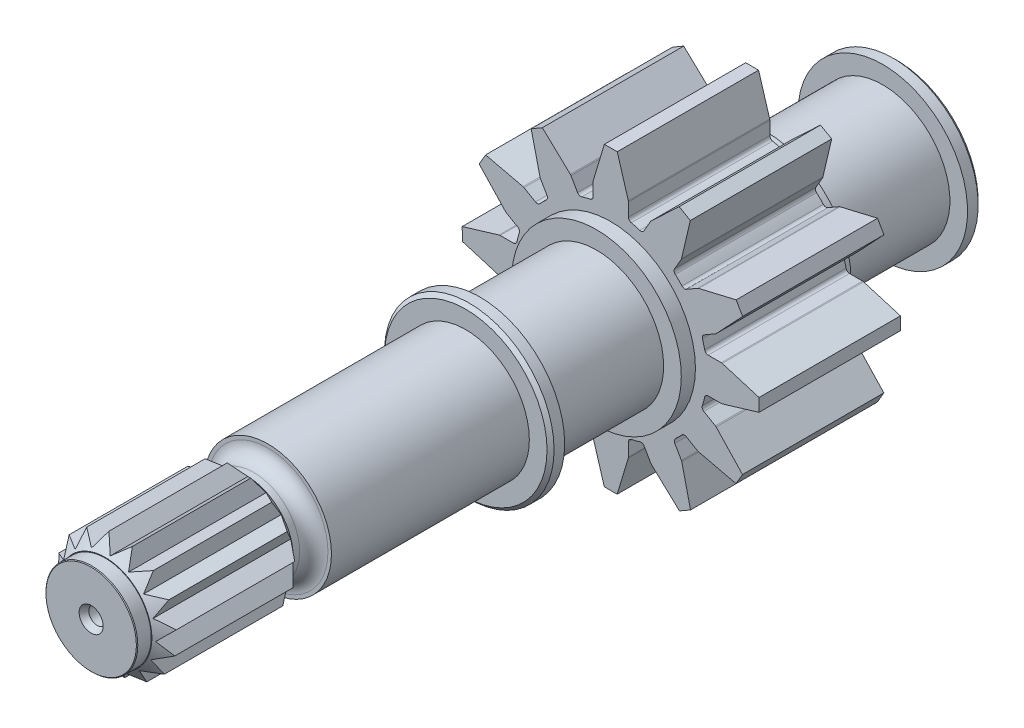
from build123d import *

# Parameters (mm, degrees)
EXTRUDE_1_DEPTH      = 20
SKETCH_3_R           = 12
EXTRUDE_2_DEPTH      = 2
SKETCH_4_R           = 12
EXTRUDE_3_DEPTH      = 2
SKETCH_5_R           = 9.5
EXTRUDE_4_DEPTH      = 16.5
SKETCH_6_R           = 12
EXTRUDE_5_DEPTH      = 2
CHAMFER_2_SIZE       = 0.5
SKETCH_7_R           = 9.5
EXTRUDE_6_DEPTH      = 16.5
SKETCH_8_R           = 12
EXTRUDE_7_DEPTH      = 2
CHAMFER_3_SIZE       = 0.5
SKETCH_10_R          = 9
EXTRUDE_9_DEPTH      = 28
SKETCH_11_R          = 6.5
EXTRUDE_10_DEPTH     = 3
FILLET_1_R           = 2
EXTRUDE_11_DEPTH     = 20
SKETCH_13_R          = 6.5
EXTRUDE_12_DEPTH     = 2
CHAMFER_5_SIZE       = 0.1
SKETCH_15_R          = 2.5
CUT_EXTRUDE_13_DEPTH = 74
CHAMFER_6_SIZE       = 0.5
CHAMFER_6_SIZE2      = 0.866025404
SKETCH_16_R          = 1
CUT_EXTRUDE_14_DEPTH = 9
SKETCH_17_R          = 1.2
CUT_EXTRUDE_15_DEPTH = 7
CHAMFER_7_SIZE       = 0.5
CHAMFER_7_SIZE2      = 0.866025404


with BuildPart() as part:
    # Эскиз2 → Вытянуть1 (new body)
    with BuildSketch(Plane.XY):
        with BuildLine():
            Line((53.764538287, -2.946020686), (53.764538287, -1.077143616))
            ThreePointArc((53.764538287, -1.077143616), (53.759197394, -1.004257629), (53.743288818, -0.932928746))
            Line((53.743288818, -0.932928746), (52.174732421, 4.274212553))
            Line((52.174732421, 4.274212553), (50.354570926, 4.274212553))
            Line((50.354570926, 4.274212553), (48.785793437, -0.932919949))
            ThreePointArc((48.785793437, -0.932919949), (48.769880615, -1.004257948), (48.764538287, -1.077153679))
            Line((48.764538287, -1.077153679), (48.764538287, -2.953138509))
            ThreePointArc((48.764538287, -2.953138509), (48.653798767, -3.266947811), (48.370633173, -3.441752748))
            ThreePointArc((48.370633173, -3.441752748), (47.755574297, -3.590379289), (47.148101498, -3.767478327))
            ThreePointArc((47.148101498, -3.767478327), (46.816157953, -3.756991645), (46.564008916, -3.540849677))
            Line((46.564008916, -3.540849677), (45.628704767, -1.920855369))
            ThreePointArc((45.628704767, -1.920855369), (45.587636424, -1.860404698), (45.538194752, -1.806586362))
            Line((45.538194752, -1.806586362), (41.576214415, 1.918652085))
            Line((41.576214415, 1.918652085), (39.999908322, 1.008571338))
            Line((39.999908322, 1.008571338), (41.244873414, -4.285326434))
            ThreePointArc((41.244873414, -4.285326434), (41.266761505, -4.355063364), (41.298582779, -4.420864083))
            Line((41.298582779, -4.420864083), (42.233043669, -6.039397823))
            ThreePointArc((42.233043669, -6.039397823), (42.29400173, -6.366811555), (42.135803463, -6.659879713))
            ThreePointArc((42.135803463, -6.659879713), (41.671118276, -7.10145189), (41.227792451, -7.564464333))
            ThreePointArc((41.227792451, -7.564464333), (40.935062472, -7.721409797), (40.608582641, -7.660306282))
            Line((40.608582641, -7.660306282), (38.980519219, -6.720343428))
            ThreePointArc((38.980519219, -6.720343428), (38.914727656, -6.688525782), (38.845000744, -6.666638572))
            Line((38.845000744, -6.666638572), (33.551205899, -5.42147761))
            Line((33.551205899, -5.42147761), (32.641125152, -6.997783703))
            Line((32.641125152, -6.997783703), (36.36624071, -10.959946087))
            ThreePointArc((36.36624071, -10.959946087), (36.42007011, -11.009400187), (36.480534902, -11.050477203))
            Line((36.480534902, -11.050477203), (38.099195221, -11.984952893))
            ThreePointArc((38.099195221, -11.984952893), (38.3156739, -12.237948594), (38.325284093, -12.570781115))
            ThreePointArc((38.325284093, -12.570781115), (38.135802793, -13.215524272), (37.978453065, -13.868852647))
            ThreePointArc((37.978453065, -13.868852647), (37.803845806, -14.152755097), (37.48960436, -14.263843393))
            Line((37.48960436, -14.263843393), (35.609921104, -14.263843393))
            ThreePointArc((35.609921104, -14.263843393), (35.536992217, -14.269190608), (35.465623196, -14.285117883))
            Line((35.465623196, -14.285117883), (30.241497591, -15.859778889))
            Line((30.241497591, -15.859778889), (30.258564934, -17.673810753))
            Line((30.258564934, -17.673810753), (35.465697436, -19.242588243))
            ThreePointArc((35.465697436, -19.242588243), (35.537035435, -19.258501065), (35.609931166, -19.263843393))
            Line((35.609931166, -19.263843393), (37.515142589, -19.263843393))
            ThreePointArc((37.515142589, -19.263843393), (37.828138332, -19.373928448), (38.003309462, -19.655708734))
            ThreePointArc((38.003309462, -19.655708734), (38.149518751, -20.25162588), (38.322513601, -20.840325449))
            ThreePointArc((38.322513601, -20.840325449), (38.312380747, -21.172625221), (38.09610656, -21.425115396))
            Line((38.09610656, -21.425115396), (36.477531273, -22.359600274))
            ThreePointArc((36.477531273, -22.359600274), (36.417080602, -22.400668616), (36.363262266, -22.450110289))
            Line((36.363262266, -22.450110289), (32.638023819, -26.412090625))
            Line((32.638023819, -26.412090625), (33.548104566, -27.988396718))
            Line((33.548104566, -27.988396718), (38.837821827, -26.744414757))
            ThreePointArc((38.837821827, -26.744414757), (38.911454943, -26.720963772), (38.980594997, -26.686446567))
            Line((38.980594997, -26.686446567), (40.557311134, -25.740478688))
            ThreePointArc((40.557311134, -25.740478688), (40.887974912, -25.674653662), (41.185251899, -25.833706677))
            ThreePointArc((41.185251899, -25.833706677), (41.655272975, -26.327509287), (42.149482788, -26.797102185))
            ThreePointArc((42.149482788, -26.797102185), (42.308189645, -27.09030597), (42.247291035, -27.418098106))
            Line((42.247291035, -27.418098106), (41.313149687, -29.036078382))
            ThreePointArc((41.313149687, -29.036078382), (41.281332042, -29.101869945), (41.259444832, -29.171596858))
            Line((41.259444832, -29.171596858), (40.014283869, -34.465391703))
            Line((40.014283869, -34.465391703), (41.590589962, -35.37547245))
            Line((41.590589962, -35.37547245), (45.552970023, -31.650152239))
            ThreePointArc((45.552970023, -31.650152239), (45.602242473, -31.596552031), (45.643208409, -31.536364418))
            Line((45.643208409, -31.536364418), (46.589687492, -29.901332509))
            ThreePointArc((46.589687492, -29.901332509), (46.841408349, -29.685740418), (47.172658361, -29.674934436))
            ThreePointArc((47.172658361, -29.674934436), (47.763729285, -29.846529298), (48.361967201, -29.991170333))
            ThreePointArc((48.361967201, -29.991170333), (48.644883646, -30.166041654), (48.75550534, -30.479704745))
            Line((48.75550534, -30.479704745), (48.75550534, -32.34734856))
            ThreePointArc((48.75550534, -32.34734856), (48.760846232, -32.420234547), (48.776754809, -32.49156343))
            Line((48.776754809, -32.49156343), (50.345311205, -37.698704729))
            Line((50.345311205, -37.698704729), (52.1654727, -37.698704729))
            Line((52.1654727, -37.698704729), (53.734250189, -32.491572227))
            ThreePointArc((53.734250189, -32.491572227), (53.750163012, -32.420234228), (53.75550534, -32.347338497))
            Line((53.75550534, -32.347338497), (53.75550534, -30.477514017))
            ThreePointArc((53.75550534, -30.477514017), (53.866087201, -30.163900379), (54.148919394, -29.989006661))
            ThreePointArc((54.148919394, -29.989006661), (54.776030579, -29.836482847), (55.395187259, -29.654337418))
            ThreePointArc((55.395187259, -29.654337418), (55.727840657, -29.664117847), (55.980669977, -29.880523195))
            Line((55.980669977, -29.880523195), (56.918293093, -31.50453407))
            ThreePointArc((56.918293093, -31.50453407), (56.959361435, -31.564984741), (57.008803108, -31.618803077))
            Line((57.008803108, -31.618803077), (60.970783444, -35.344041525))
            Line((60.970783444, -35.344041525), (62.547089537, -34.433960777))
            Line((62.547089537, -34.433960777), (61.302124446, -29.140063005))
            ThreePointArc((61.302124446, -29.140063005), (61.280236354, -29.070326075), (61.248415081, -29.004525356))
            Line((61.248415081, -29.004525356), (60.313352567, -27.384949575))
            ThreePointArc((60.313352567, -27.384949575), (60.252285616, -27.058233892), (60.409547147, -26.765418044))
            ThreePointArc((60.409547147, -26.765418044), (60.874734414, -26.320800568), (61.318355435, -25.854662946))
            ThreePointArc((61.318355435, -25.854662946), (61.611362594, -25.69669226), (61.938606865, -25.757676849))
            Line((61.938606865, -25.757676849), (63.556770089, -26.691923822))
            ThreePointArc((63.556770089, -26.691923822), (63.622561652, -26.723741467), (63.692288565, -26.745628677))
            Line((63.692288565, -26.745628677), (68.986083409, -27.990789639))
            Line((68.986083409, -27.990789639), (69.896164156, -26.414483546))
            Line((69.896164156, -26.414483546), (66.171043874, -22.452316137))
            ThreePointArc((66.171043874, -22.452316137), (66.117219766, -22.402866229), (66.056761375, -22.361791772))
            Line((66.056761375, -22.361791772), (64.43714748, -21.426707253))
            ThreePointArc((64.43714748, -21.426707253), (64.220913014, -21.174319639), (64.210673714, -20.84212691))
            ThreePointArc((64.210673714, -20.84212691), (64.390016693, -20.228801746), (64.540344527, -19.607727513))
            ThreePointArc((64.540344527, -19.607727513), (64.715163733, -19.324615398), (65.028941656, -19.213901173))
            Line((65.028941656, -19.213901173), (66.888769323, -19.213901173))
            ThreePointArc((66.888769323, -19.213901173), (66.961655311, -19.208560281), (67.032984194, -19.192651704))
            Line((67.032984194, -19.192651704), (72.240125492, -17.624095307))
            Line((72.240125492, -17.624095307), (72.240125492, -15.803933813))
            Line((72.240125492, -15.803933813), (67.033013036, -14.235162363))
            ThreePointArc((67.033013036, -14.235162363), (66.961654766, -14.219246553), (66.888738326, -14.213907214))
            Line((66.888738326, -14.213907214), (65.038418761, -14.214058869))
            ThreePointArc((65.038418761, -14.214058869), (64.724765213, -14.103477871), (64.549862276, -13.820607462))
            ThreePointArc((64.549862276, -13.820607462), (64.40200748, -13.210628208), (64.226184375, -12.608115166))
            ThreePointArc((64.226184375, -12.608115166), (64.236662079, -12.276162568), (64.452807408, -12.024004868))
            Line((64.452807408, -12.024004868), (66.072795877, -11.088704089))
            ThreePointArc((66.072795877, -11.088704089), (66.133246547, -11.047635747), (66.187064884, -10.998194074))
            Line((66.187064884, -10.998194074), (69.912303331, -7.036213738))
            Line((69.912303331, -7.036213738), (69.002222584, -5.459907645))
            Line((69.002222584, -5.459907645), (63.708324812, -6.704872737))
            ThreePointArc((63.708324812, -6.704872737), (63.638587881, -6.726760828), (63.572787163, -6.758582102))
            Line((63.572787163, -6.758582102), (61.954455243, -7.692926471))
            ThreePointArc((61.954455243, -7.692926471), (61.626900937, -7.75386248), (61.3337823, -7.595475342))
            ThreePointArc((61.3337823, -7.595475342), (60.870851004, -7.108824873), (60.384451797, -6.645629585))
            ThreePointArc((60.384451797, -6.645629585), (60.226244716, -6.352559068), (60.287201748, -6.025138774))
            Line((60.287201748, -6.025138774), (61.21857227, -4.41195771))
            ThreePointArc((61.21857227, -4.41195771), (61.250389916, -4.346166146), (61.272277126, -4.276439234))
            Line((61.272277126, -4.276439234), (62.517438088, 1.017355611))
            Line((62.517438088, 1.017355611), (60.941131995, 1.927436358))
            Line((60.941131995, 1.927436358), (56.978964585, -1.797683924))
            ThreePointArc((56.978964585, -1.797683924), (56.929514677, -1.851508033), (56.88844022, -1.911966424))
            Line((56.88844022, -1.911966424), (55.953232083, -3.531794433))
            ThreePointArc((55.953232083, -3.531794433), (55.70097994, -3.747976393), (55.368928673, -3.758356204))
            ThreePointArc((55.368928673, -3.758356204), (54.767086452, -3.582459006), (54.157776241, -3.434489586))
            ThreePointArc((54.157776241, -3.434489586), (53.875063626, -3.259564126), (53.764538287, -2.946020686))
        make_face()
    extrude(amount=EXTRUDE_1_DEPTH)

    # Эскиз3 → Вытянуть2 (add)
    with BuildSketch(Plane(origin=(0, 0, 0), x_dir=(-1, 0, 0), z_dir=(0, 0, -1))):
        with Locations(Location((-51.240125492, -16.733104028, 0), (0, 0, 180))):
            Circle(SKETCH_3_R)
    extrude(amount=EXTRUDE_2_DEPTH)

    # Эскиз4 → Вытянуть3 (add)
    with BuildSketch(Plane.XY.offset(20)):
        with Locations((51.240125492, -16.733104028)):
            Circle(SKETCH_4_R)
    extrude(amount=EXTRUDE_3_DEPTH)

    # Эскиз5 → Вытянуть4 (add)
    with BuildSketch(Plane(origin=(0, 0, -2), x_dir=(-1, 0, 0), z_dir=(0, 0, -1))):
        with Locations((-51.240125492, -16.733104028)):
            Circle(SKETCH_5_R)
    extrude(amount=EXTRUDE_4_DEPTH)

    # Эскиз6 → Вытянуть5 (add)
    with BuildSketch(Plane(origin=(0, 0, -18.5), x_dir=(-1, 0, 0), z_dir=(0, 0, -1))):
        with Locations(Location((-51.240125492, -16.733104028, 0), (0, 0, 180))):
            Circle(SKETCH_6_R)
    extrude(amount=EXTRUDE_5_DEPTH)

    # Фаска2
    chamfer_2_edges = [part.edges().sort_by_distance(p)[0] for p in [
        (39.240125492, -16.733104028, -20.5),
    ]]
    chamfer(chamfer_2_edges, length=CHAMFER_2_SIZE)

    # Эскиз7 → Вытянуть6 (add)
    with BuildSketch(Plane.XY.offset(22)):
        with Locations(Location((51.240125492, -16.733104028, 0), (0, 0, 180))):
            Circle(SKETCH_7_R)
    extrude(amount=EXTRUDE_6_DEPTH)

    # Эскиз8 → Вытянуть7 (add)
    with BuildSketch(Plane.XY.offset(38.5)):
        with Locations((51.240125492, -16.733104028)):
            Circle(SKETCH_8_R)
    extrude(amount=EXTRUDE_7_DEPTH)

    # Фаска3
    chamfer_3_edges = [part.edges().sort_by_distance(p)[0] for p in [
        (39.240125492, -16.733104028, 40.5),
    ]]
    chamfer(chamfer_3_edges, length=CHAMFER_3_SIZE)

    # Эскиз10 → Вытянуть9 (add)
    with BuildSketch(Plane.XY.offset(40.5)):
        with Locations((51.240125492, -16.733104028)):
            Circle(SKETCH_10_R)
    extrude(amount=EXTRUDE_9_DEPTH)

    # Эскиз11 → Вытянуть10 (add)
    with BuildSketch(Plane.XY.offset(68.5)):
        with Locations((51.240125492, -16.733104028)):
            Circle(SKETCH_11_R)
    extrude(amount=EXTRUDE_10_DEPTH)

    # Скругление1
    fillet_1_edges = [part.edges().sort_by_distance(p)[0] for p in [
        (44.740125492, -16.733104028, 68.5),
    ]]
    fillet(fillet_1_edges, radius=FILLET_1_R)

    # Эскиз12 → Вытянуть11 (add)
    with BuildSketch(Plane.XY.offset(71.5)):
        Polygon((52.350047055, -25.160326235), (53.45804216, -23.230479976), (55.490517626, -24.094093548), (55.775651435, -21.887136718), (57.983904525, -21.907216934), (57.402768001, -19.759138705), (59.450612199, -18.932628533), (58.091678108, -17.170454343), (59.667347699, -15.623182466), (57.73750144, -14.515187361), (58.601115012, -12.482711894), (56.394158182, -12.197578085), (56.414238398, -9.989324996), (54.266160169, -10.57046152), (53.439649998, -8.522617322), (51.677475807, -9.881551412), (50.13020393, -8.305881821), (49.022208825, -10.235728081), (46.989733359, -9.372114508), (46.70459955, -11.579071338), (44.49634646, -11.558991122), (45.077482984, -13.707069351), (43.029638786, -14.533579523), (44.388572877, -16.295753713), (42.812903286, -17.843025591), (44.742749545, -18.951020696), (43.879135973, -20.983496162), (46.086092803, -21.268629971), (46.066012587, -23.476883061), (48.214090816, -22.895746536), (49.040600987, -24.943590734), (50.802775178, -23.584656644), align=None)
    extrude(amount=EXTRUDE_11_DEPTH)

    # Эскиз13 → Вытянуть12 (add)
    with BuildSketch(Plane.XY.offset(91.5)):
        with Locations((51.240125492, -16.733104028)):
            Circle(SKETCH_13_R)
    extrude(amount=EXTRUDE_12_DEPTH)

    # Вырез-По траектории1: sweep along a curve in space
    with BuildLine() as sweep_1_path:
        ThreePointArc((57.740125492, -16.733104028, 71.5), (55.83631957, -12.13690995, 71.5), (51.240125492, -10.233104028, 71.5))
        ThreePointArc((51.240125492, -10.233104028, 71.5), (46.643931415, -12.13690995, 71.5), (44.740125492, -16.733104028, 71.5))
        ThreePointArc((44.740125492, -16.733104028, 71.5), (46.643931415, -21.329298106, 71.5), (51.240125492, -23.233104028, 71.5))
        ThreePointArc((51.240125492, -23.233104028, 71.5), (55.83631957, -21.329298106, 71.5), (57.740125492, -16.733104028, 71.5))
    # Эскиз14 → Вырез-По траектории1 (sweep, cut)
    with BuildSketch(Plane(origin=(19.954700446, 15.388446186, 0), x_dir=(0, 0, 1), z_dir=(-0.7918816576628084, -0.6106745780341628, 0))):
        Polygon((71.451586323, -40.520434253), (73.210876948, -37.651126648), (70.798909374, -37.651126648), align=None)
    sweep_1 = sweep(path=sweep_1_path.line, mode=Mode.SUBTRACT)

    # Зеркальное отражение1: Вырез-По траектории1 across plane
    add(sweep_1.mirror(Plane.XY.offset(81.5)), mode=Mode.SUBTRACT)

    # Зеркальное отражение2 copy 1: sweep along a curve in space
    with BuildLine() as mirror_2_copy_1_path:
        ThreePointArc((57.740125492, -16.733104028, 71.5), (55.83631957, -12.13690995, 71.5), (51.240125492, -10.233104028, 71.5))
        ThreePointArc((51.240125492, -10.233104028, 71.5), (46.643931415, -12.13690995, 71.5), (44.740125492, -16.733104028, 71.5))
        ThreePointArc((44.740125492, -16.733104028, 71.5), (46.643931415, -21.329298106, 71.5), (51.240125492, -23.233104028, 71.5))
        ThreePointArc((51.240125492, -23.233104028, 71.5), (55.83631957, -21.329298106, 71.5), (57.740125492, -16.733104028, 71.5))
    # Зеркальное отражение2 copy 1 sketch → Зеркальное отражение2 copy 1 (sweep, cut)
    with BuildSketch(Plane(origin=(19.954700446, 15.388446186, 0), x_dir=(0, 0, 1), z_dir=(-0.7918816576628084, -0.6106745780341628, 0))):
        Polygon((71.451586323, -40.520434253), (73.210876948, -37.651126648), (70.798909374, -37.651126648), align=None)
    sweep(path=mirror_2_copy_1_path.line, mode=Mode.SUBTRACT)

    # Зеркальное отражение2 copy 2: sweep along a curve in space
    with BuildLine() as mirror_2_copy_2_path:
        ThreePointArc((57.740125492, -16.733104028, 91.5), (55.83631957, -12.13690995, 91.5), (51.240125492, -10.233104028, 91.5))
        ThreePointArc((51.240125492, -10.233104028, 91.5), (46.643931415, -12.13690995, 91.5), (44.740125492, -16.733104028, 91.5))
        ThreePointArc((44.740125492, -16.733104028, 91.5), (46.643931415, -21.329298106, 91.5), (51.240125492, -23.233104028, 91.5))
        ThreePointArc((51.240125492, -23.233104028, 91.5), (55.83631957, -21.329298106, 91.5), (57.740125492, -16.733104028, 91.5))
    # Зеркальное отражение2 copy 2 sketch → Зеркальное отражение2 copy 2 (sweep, cut)
    with BuildSketch(Plane(origin=(19.954700446, 15.388446186, 163), x_dir=(0, 0, -1), z_dir=(-0.7918816576628084, -0.6106745780341628, 0))):
        Polygon((71.451586323, 40.520434253), (73.210876948, 37.651126648), (70.798909374, 37.651126648), align=None)
    sweep(path=mirror_2_copy_2_path.line, mode=Mode.SUBTRACT)

    # Фаска5
    chamfer_5_edges = [part.edges().sort_by_distance(p)[0] for p in [
        (44.740125492, -16.733104028, 93.5),
    ]]
    chamfer(chamfer_5_edges, length=CHAMFER_5_SIZE)

    # Эскиз15 → Вытянуть13 (cut)
    with BuildSketch(Plane(origin=(0, 0, -20.5), x_dir=(-1, 0, 0), z_dir=(0, 0, -1))):
        with Locations((-51.240125492, -16.733104028)):
            Circle(SKETCH_15_R)
    extrude(amount=-CUT_EXTRUDE_13_DEPTH, mode=Mode.SUBTRACT)

    # Фаска6
    chamfer_6_edges = [part.edges().sort_by_distance(p)[0] for p in [
        (53.740125492, -16.733104028, -20.5),
    ]]
    chamfer_6_side = [part.faces().sort_by_distance(p)[0] for p in [
        (40.065394612, -16.733104028, -20.5),
    ]]
    chamfer(chamfer_6_edges, length=CHAMFER_6_SIZE, length2=CHAMFER_6_SIZE2, reference=chamfer_6_side[0])

    # Эскиз16 → Вытянуть14 (cut)
    with BuildSketch(Plane(origin=(40, 0, 0), x_dir=(0, 0, -1), z_dir=(1, 0, 0))):
        with Locations(Location((-44.658264315, -16.30213081, 0), (0, 0, 205.52933887))):
            Circle(SKETCH_16_R)
    extrude(amount=CUT_EXTRUDE_14_DEPTH, mode=Mode.SUBTRACT)

    # Эскиз17 → Вытянуть15 (cut)
    with BuildSketch(Plane.XY.offset(93.5)):
        with Locations((51.240125492, -16.733104028)):
            Circle(SKETCH_17_R)
    extrude(amount=-CUT_EXTRUDE_15_DEPTH, mode=Mode.SUBTRACT)

    # Фаска7
    chamfer_7_edges = [part.edges().sort_by_distance(p)[0] for p in [
        (50.040125492, -16.733104028, 93.5),
    ]]
    chamfer_7_side = [part.faces().sort_by_distance(p)[0] for p in [
        (45.021144828, -16.733104028, 93.5),
    ]]
    chamfer(chamfer_7_edges, length=CHAMFER_7_SIZE, length2=CHAMFER_7_SIZE2, reference=chamfer_7_side[0])


solid = part.part
